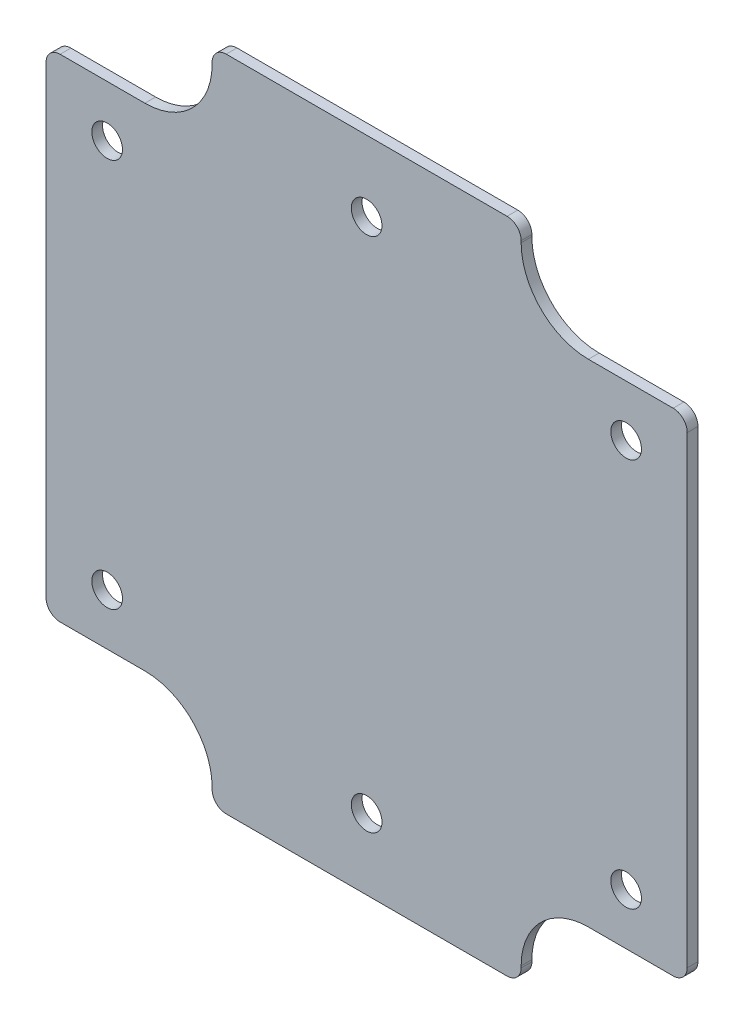
from build123d import *

# Parameters (mm, degrees)
SKETCH1_R      = 1.7145
MAINBODY_DEPTH = 1.2
LARGEROUNDS_R  = 7.5184
SMALLROUNDS_R  = 1.5748


with BuildPart() as part:
    # Sketch1 → MainBody (new body)
    with BuildSketch(Plane.XY):
        Polygon((71.6788, -27.4828), (71.6788, 27.4828), (53.1114, 27.4828), (53.1114, 36.7792), (18.5674, 36.7792), (18.5674, 27.4828), (0, 27.4828), (0, -27.4828), (18.5674, -27.4828), (18.5674, -36.7792), (53.1114, -36.7792), (53.1114, -27.4828), align=None)
        with Locations((64.8462, -21.7424)):
            Circle(SKETCH1_R, mode=Mode.SUBTRACT)
        with Locations((6.8326, -21.7424)):
            Circle(SKETCH1_R, mode=Mode.SUBTRACT)
        with Locations((6.8326, 21.7424)):
            Circle(SKETCH1_R, mode=Mode.SUBTRACT)
        with Locations((64.8462, 21.7424)):
            Circle(SKETCH1_R, mode=Mode.SUBTRACT)
        with Locations((35.8394, -28.8671)):
            Circle(SKETCH1_R, mode=Mode.SUBTRACT)
        with Locations((35.8394, 28.8671)):
            Circle(SKETCH1_R, mode=Mode.SUBTRACT)
    extrude(amount=MAINBODY_DEPTH)

    # LargeRounds
    largerounds_edges = [part.edges().sort_by_distance(p)[0] for p in [
        (53.1114, -27.4828, 0.6),
        (18.5674, -27.4828, 0.6),
        (18.5674, 27.4828, 0.6),
        (53.1114, 27.4828, 0.6),
    ]]
    fillet(largerounds_edges, radius=LARGEROUNDS_R)

    # SmallRounds
    smallrounds_edges = [part.edges().sort_by_distance(p)[0] for p in [
        (53.1114, -36.7792, 0.6),
        (18.5674, -36.7792, 0.6),
        (0, -27.4828, 0.6),
        (0, 27.4828, 0.6),
        (18.5674, 36.7792, 0.6),
        (53.1114, 36.7792, 0.6),
        (71.6788, 27.4828, 0.6),
        (71.6788, -27.4828, 0.6),
    ]]
    fillet(smallrounds_edges, radius=SMALLROUNDS_R)


solid = part.part
